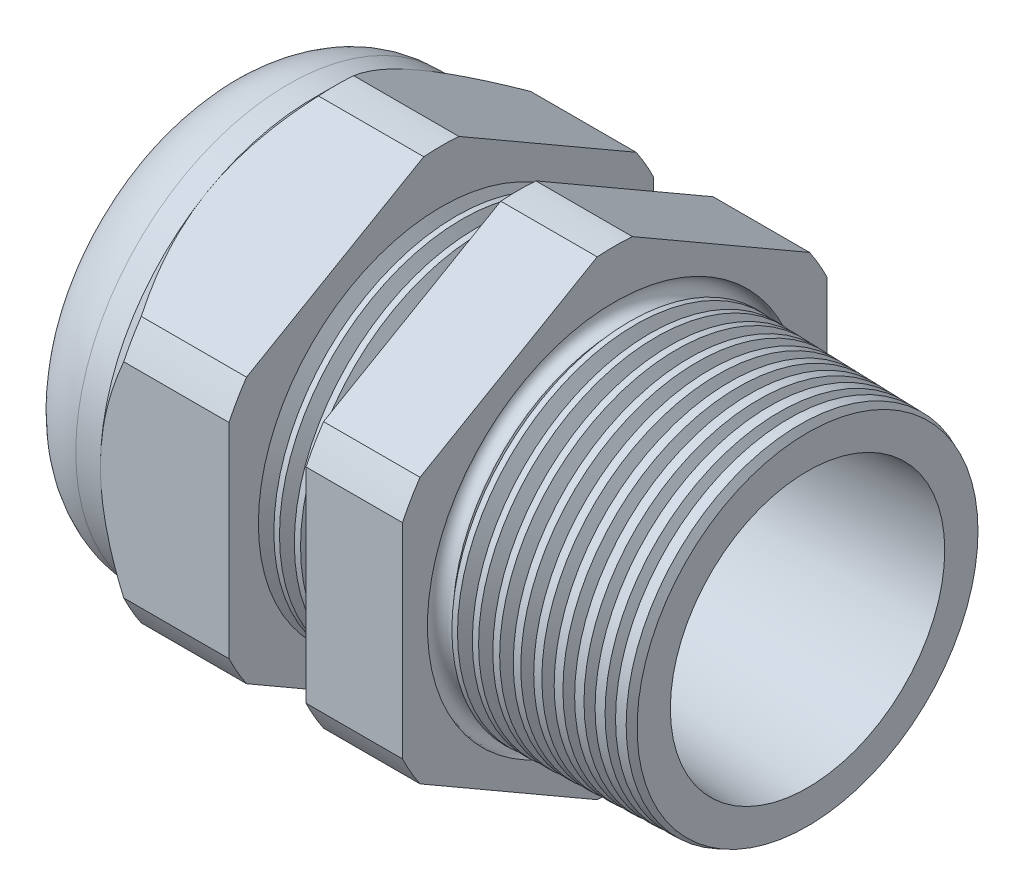
from build123d import *

# Parameters (mm, degrees)
LPATTERN6_COUNT    = 4
LPATTERN6_PITCH    = 1.5748
LPATTERN7_COUNT    = 10
LPATTERN7_PITCH    = 1.5748
SKETCH12_OUTSIDE_W = 88.86
SKETCH12_OUTSIDE_H = 88.86
CUT_EXTRUDE2_DEPTH = 39.474
FILLET4_R          = 5.588
SKETCH19_OUTSIDE_W = 56.502
SKETCH19_OUTSIDE_H = 60.134
SKETCH19_OUTSIDE_R = 16.51
CUT_EXTRUDE3_DEPTH = 3.99796
CUT_EXTRUDE3_DRAFT = -45
SKETCH28_R         = 0.8255


with BuildPart() as part:
    # Sketch10 → Revolve2 (revolve)
    with BuildSketch(Plane.XY, mode=Mode.PRIVATE) as revolve2_sk:
        Polygon((-31.362, 9.017), (-21.362, 9.017), (7.112, 10.668), (7.112, 13.478382069), (-7.874, 13.87080429), (-7.874, 33.02), (-15.374, 33.02), (-15.374, 14.067198702), (-21.362, 14.224), (-21.362, 33.02), (-31.362, 33.02), (-31.362, 16.51), (-38.862, 16.51), (-38.862, 10.668), (-31.362, 10.668), align=None)
    revolve(revolve2_sk.sketch.rotate(Axis((0, 0, 0), (-1, 0, 0)), 90), axis=Axis((0, 0, 0), (-1, 0, 0)))  # turned: the seam where the file's is

    # Sketch26 → Cut-Revolve1 (revolve, cut)
    with BuildSketch(Plane.XY, mode=Mode.PRIVATE) as cut_revolve1_sk:
        Polygon((-21.362, 14.224), (-20.189226271, 14.193289839), (-20.802208915, 13.192993077), align=None)
    cut_revolve1 = revolve(cut_revolve1_sk.sketch.rotate(Axis((0, 0, 0), (-1, 0, 0)), 90), axis=Axis((0, 0, 0), (-1, 0, 0)), mode=Mode.SUBTRACT)  # turned: the seam where the file's is

    # LPattern6: Cut-Revolve1 ×4
    with Locations(*[(i * LPATTERN6_PITCH, 0, 0) for i in range(1, LPATTERN6_COUNT)]):
        add(cut_revolve1, mode=Mode.SUBTRACT)

    # Sketch27 → Cut-Revolve2 (revolve, cut)
    with BuildSketch(Plane.XY, mode=Mode.PRIVATE) as cut_revolve2_sk:
        Polygon((-7.874, 13.87080429), (-6.701226271, 13.840094129), (-7.314208915, 12.839797367), align=None)
    cut_revolve2 = revolve(cut_revolve2_sk.sketch.rotate(Axis((0, 0, 0), (-1, 0, 0)), 90), axis=Axis((0, 0, 0), (-1, 0, 0)), mode=Mode.SUBTRACT)  # turned: the seam where the file's is

    # LPattern7: Cut-Revolve2 ×10
    with Locations(*[(i * LPATTERN7_PITCH, 0, 0) for i in range(1, LPATTERN7_COUNT)]):
        add(cut_revolve2, mode=Mode.SUBTRACT)

    # Sketch12 outside → Cut-Extrude2 (cut, through all)
    with BuildSketch(Plane.ZY.offset(31.362)):
        Rectangle(SKETCH12_OUTSIDE_W, SKETCH12_OUTSIDE_H)
        with BuildLine():
            Line((-1.366648898, 18.27507078), (-15.143351102, 10.321088053))
            ThreePointArc((-15.143351102, 10.321088053), (-15.870868152, 9.16305), (-16.51, 7.953982726))
            Line((-16.51, 7.953982726), (-16.51, -7.953982726))
            ThreePointArc((-16.51, -7.953982726), (-15.870868152, -9.16305), (-15.143351102, -10.321088053))
            Line((-15.143351102, -10.321088053), (-1.366648898, -18.27507078))
            ThreePointArc((-1.366648898, -18.27507078), (0, -18.3261), (1.366648898, -18.27507078))
            Line((1.366648898, -18.27507078), (15.143351102, -10.321088053))
            ThreePointArc((15.143351102, -10.321088053), (15.870868152, -9.16305), (16.51, -7.953982726))
            Line((16.51, -7.953982726), (16.51, 7.953982726))
            ThreePointArc((16.51, 7.953982726), (15.870868152, 9.16305), (15.143351102, 10.321088053))
            Line((15.143351102, 10.321088053), (1.366648898, 18.27507078))
            ThreePointArc((1.366648898, 18.27507078), (0, 18.3261), (-1.366648898, 18.27507078))
        make_face(mode=Mode.SUBTRACT)
    extrude(amount=-CUT_EXTRUDE2_DEPTH, mode=Mode.SUBTRACT)

    # Fillet4
    fillet4_edges = [part.edges().sort_by_distance(p)[0] for p in [
        (-38.862, 0, 16.51),
    ]]
    fillet(fillet4_edges, radius=FILLET4_R)


with BuildPart() as body_2:
    # Sketch23 → Revolve6 (revolve)
    with BuildSketch(Plane.XY, mode=Mode.PRIVATE) as revolve6_sk:
        with BuildLine():
            Line((-37.8714, 10.668), (-31.362, 10.668))
            Line((-31.362, 10.668), (-31.362, 9.017))
            Line((-31.362, 9.017), (-38.1, 9.017))
            Line((-38.1, 9.017), (-38.1, 10.4394))
            ThreePointArc((-38.1, 10.4394), (-38.03304461, 10.60104461), (-37.8714, 10.668))
        make_face()
    revolve(revolve6_sk.sketch.rotate(Axis((0, 0, 0), (-1, 0, 0)), 90), axis=Axis((0, 0, 0), (-1, 0, 0)))  # turned: the seam where the file's is


with BuildPart() as cut_extrude3_tool:
    # Sketch19 outside → Cut-Extrude3 (with draft: the straight prism first)
    with BuildSketch(Plane.ZY.offset(31.362)):
        Rectangle(SKETCH19_OUTSIDE_W, SKETCH19_OUTSIDE_H)
        Circle(SKETCH19_OUTSIDE_R, mode=Mode.SUBTRACT)
    extrude(amount=-CUT_EXTRUDE3_DEPTH)
    # Cut-Extrude3: the draft: its side faces are tilted about the plane it starts from
    cut_extrude3_sides = [cut_extrude3_tool.faces().sort_by_distance(p)[0] for p in [
        (-29.36302, -30.067, 0),
        (-29.36302, 0, 28.251),
        (-29.36302, 30.067, 0),
        (-29.36302, 0, -28.251),
        (-29.36302, 0, -16.51),
    ]]
    draft(cut_extrude3_sides, Plane.ZY.offset(31.362), CUT_EXTRUDE3_DRAFT)


with BuildPart() as part_1:
    add(part.part)

    # Cut-Extrude3: cut by cut_extrude3_tool
    add(cut_extrude3_tool.part, mode=Mode.SUBTRACT)

    # Sketch28 → Cut-Revolve3 (revolve, cut)
    with BuildSketch(Plane.XY, mode=Mode.PRIVATE) as cut_revolve3_sk:
        with Locations((-7.8486, -13.74380429)):
            Circle(SKETCH28_R)
    revolve(cut_revolve3_sk.sketch.rotate(Axis((7.112, 0, 0), (-1, 0, 0)), 90), axis=Axis((7.112, 0, 0), (-1, 0, 0)), mode=Mode.SUBTRACT)  # turned: the seam where the file's is


solid = Compound([body_2.part, part_1.part])
